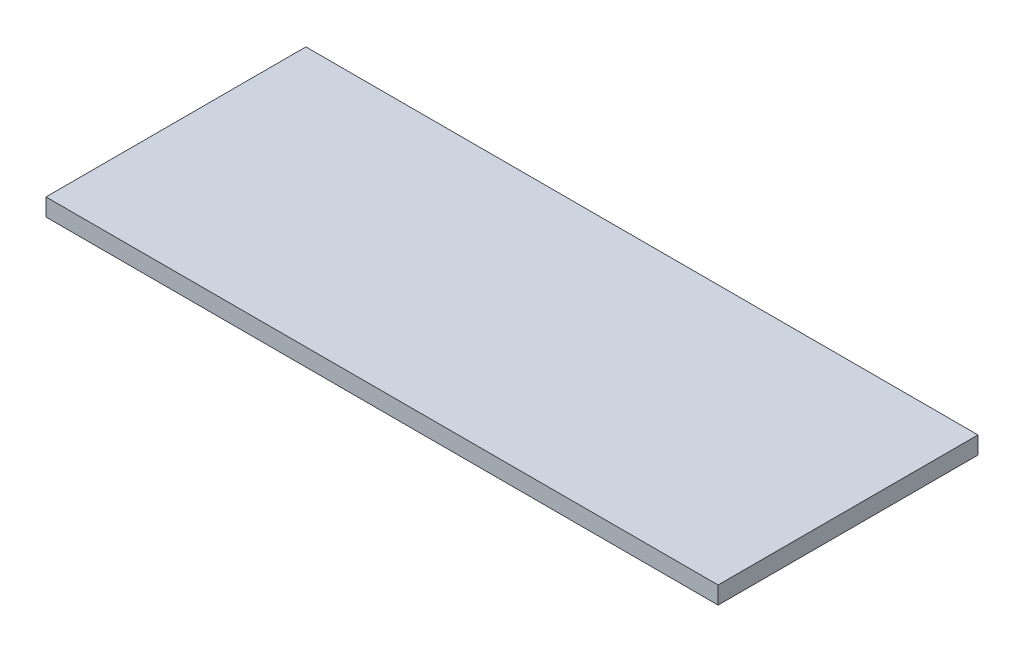
from build123d import *

# Parameters (mm, degrees)
SKETCH1_W           = 132.41
SKETCH1_H           = 51.2
BOSS_EXTRUDE1_DEPTH = 3.44


with BuildPart() as part:
    # Sketch1 → Boss-Extrude1 (new body)
    with BuildSketch(Plane(origin=(0, 0, 0), x_dir=(1, 0, 0), z_dir=(0, 1, 0))):
        Rectangle(SKETCH1_W, SKETCH1_H)
    extrude(amount=BOSS_EXTRUDE1_DEPTH)


solid = part.part
